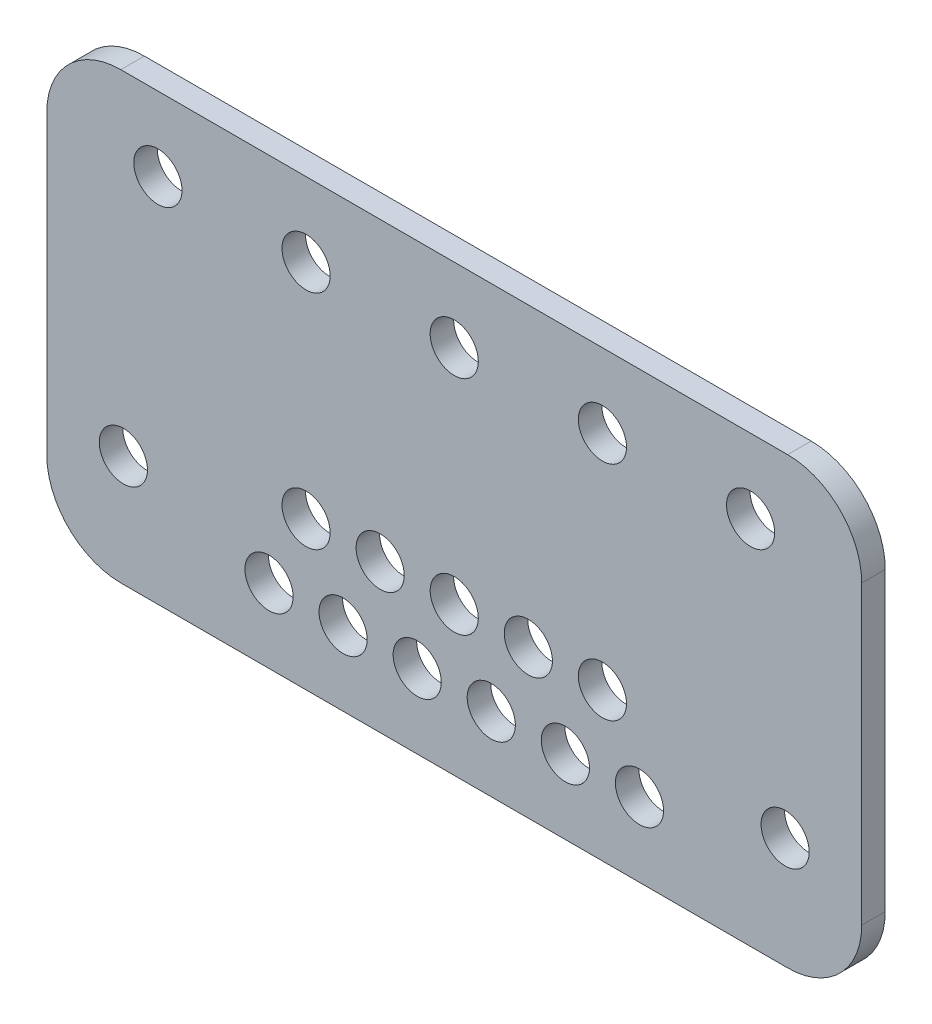
from build123d import *

# Parameters (mm, degrees)
SKETCH1_W           = 110
SKETCH1_H           = 60
BOSS_EXTRUDE1_DEPTH = 3.175
SKETCH2_R           = 3.25
CUT_EXTRUDE1_DEPTH  = 4.175
FILLET1_R           = 10


with BuildPart() as part:
    # Sketch1 → Boss-Extrude1 (new body)
    with BuildSketch(Plane.XY):
        Rectangle(SKETCH1_W, SKETCH1_H)
    extrude(amount=BOSS_EXTRUDE1_DEPTH)

    # Sketch2 → Cut-Extrude1 (cut, through all)
    with BuildSketch(Plane.XY.offset(3.175)):
        with Locations((-40, 20)):
            Circle(SKETCH2_R)
        with Locations((40, 20)):
            Circle(SKETCH2_R)
        with Locations((-20, 20)):
            Circle(SKETCH2_R)
        with Locations((0, 20)):
            Circle(SKETCH2_R)
        with Locations((20, 20)):
            Circle(SKETCH2_R)
        with Locations((44.66, -15)):
            Circle(SKETCH2_R)
        with Locations((5, -20)):
            Circle(SKETCH2_R)
        with Locations((0, -10)):
            Circle(SKETCH2_R)
        with Locations((-5, -20)):
            Circle(SKETCH2_R)
        with Locations((-10, -10)):
            Circle(SKETCH2_R)
        with Locations((-15, -20)):
            Circle(SKETCH2_R)
        with Locations((10, -10)):
            Circle(SKETCH2_R)
        with Locations((-20, -10)):
            Circle(SKETCH2_R)
        with Locations((-44.66, -15)):
            Circle(SKETCH2_R)
        with Locations((20, -10)):
            Circle(SKETCH2_R)
        with Locations((15, -20)):
            Circle(SKETCH2_R)
        with Locations((-25, -20)):
            Circle(SKETCH2_R)
        with Locations((25, -20)):
            Circle(SKETCH2_R)
    extrude(amount=-CUT_EXTRUDE1_DEPTH, mode=Mode.SUBTRACT)

    # Fillet1
    fillet1_edges = [part.edges().sort_by_distance(p)[0] for p in [
        (55, -30, 1.5875),
        (-55, -30, 1.5875),
        (-55, 30, 1.5875),
        (55, 30, 1.5875),
    ]]
    fillet(fillet1_edges, radius=FILLET1_R)


solid = part.part
